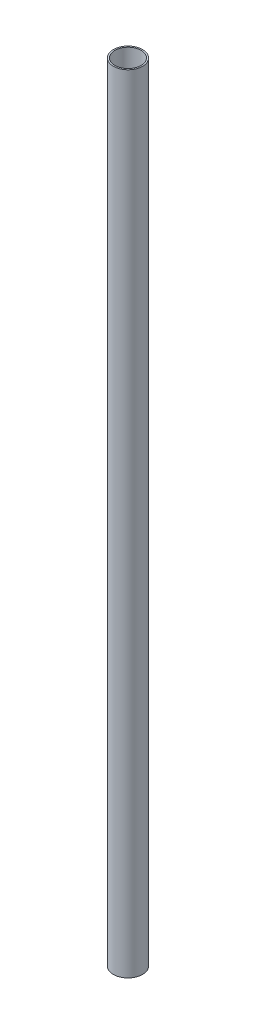
from build123d import *

# Parameters (mm, degrees)
SKETCH1_R                       = 0.5
SKETCH1_R_2                     = 0.45
BOSS_EXTRUDE1_DEPTH             = 27
F_0_5_0_5_DIAMETER_HOLE1_REACH  = 16.852
F_0_5_0_5_DIAMETER_HOLE1_BORE_R = 0.25


with BuildPart() as part:
    # Sketch1 → Boss-Extrude1 (new body)
    with BuildSketch(Plane(origin=(0, 0, 0), x_dir=(1, 0, 0), z_dir=(0, 1, 0))):
        with Locations(Location((0, 0, 0), (0, 0, 270))):
            Circle(SKETCH1_R)
        with Locations(Location((0, 0, 0), (0, 0, 270))):
            Circle(SKETCH1_R_2, mode=Mode.SUBTRACT)
    extrude(amount=BOSS_EXTRUDE1_DEPTH)

    # Ø0.5 (0.5) Diameter Hole1 bore (on position points) → Ø0.5 (0.5) Diameter Hole1 (cut, up to next)
    with BuildSketch(Plane(origin=(-0.006079101, 14.81, -0.499963043), x_dir=(-0.999926086337, 0, 0.012158201471), z_dir=(-0.012158201471, 0, -0.999926086337)), mode=Mode.PRIVATE) as f_0_5_0_5_diameter_hole1_sk1:
        Circle(F_0_5_0_5_DIAMETER_HOLE1_BORE_R)
    f_0_5_0_5_diameter_hole1_tool1 = extrude(f_0_5_0_5_diameter_hole1_sk1.sketch, amount=-F_0_5_0_5_DIAMETER_HOLE1_REACH, mode=Mode.PRIVATE) & part.part
    add(f_0_5_0_5_diameter_hole1_tool1.solids().sort_by_distance((-0.006079, 14.81, -0.499963))[0], mode=Mode.SUBTRACT)


solid = part.part
